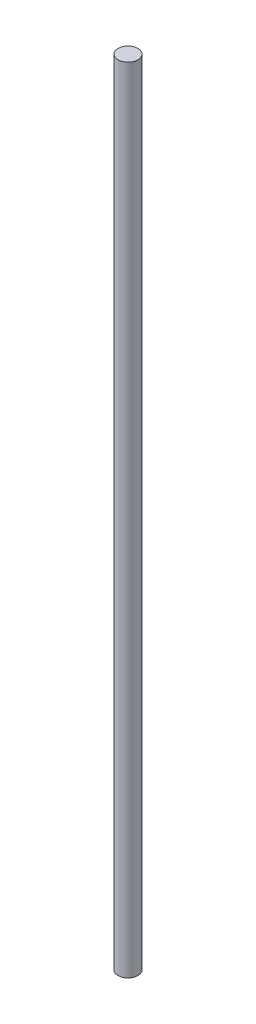
from build123d import *

# Parameters (mm, degrees)
SKETCH1_R           = 5
BOSS_EXTRUDE1_DEPTH = 400


with BuildPart() as part:
    # Sketch1 → Boss-Extrude1 (new body)
    with BuildSketch(Plane(origin=(0, 0, 0), x_dir=(1, 0, 0), z_dir=(0, 1, 0))):
        Circle(SKETCH1_R)
    extrude(amount=BOSS_EXTRUDE1_DEPTH)


solid = part.part
